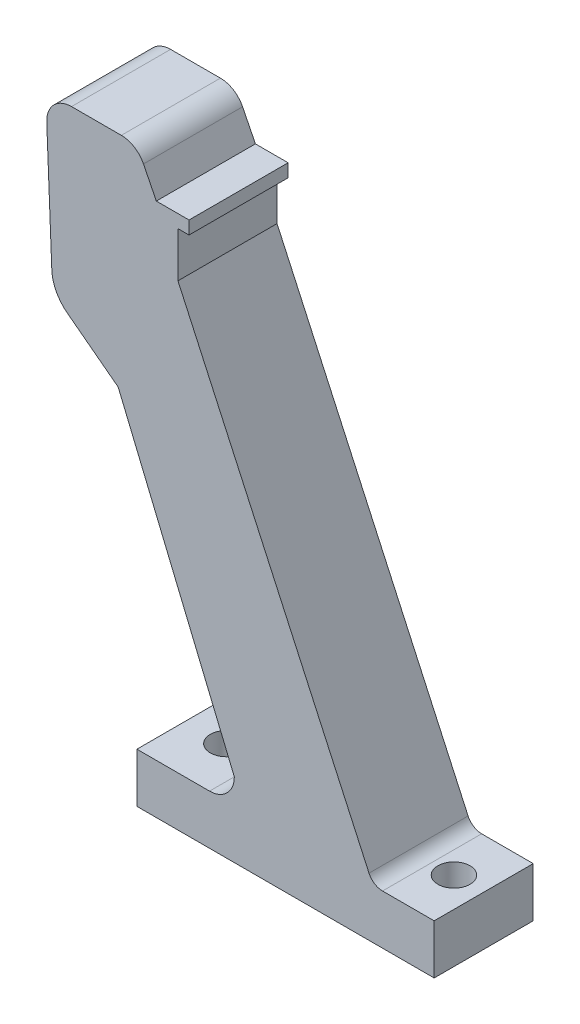
from build123d import *

# Parameters (mm, degrees)
BOSS_EXTRUDE1_DEPTH     = 20
SKETCH3_R               = 3.25
CUT_EXTRUDE1_DEPTH      = 20
CUT_EXTRUDE1_DEPTH_BACK = 20


with BuildPart() as part:
    # Sketch1 → Boss-Extrude1 (new body)
    with BuildSketch(Plane.XY):
        with BuildLine():
            Line((-44.097792079, -34.850100287), (-44.097792079, -44.850100287))
            Line((-44.097792079, -44.850100287), (15.902191644, -44.850100287))
            Line((15.902191644, -44.850100287), (15.902191644, -34.850100287))
            Line((15.902191644, -34.850100287), (5.481837679, -34.850100287))
            ThreePointArc((5.481837679, -34.850100287), (3.860980617, -34.374545252), (2.753994712, -33.098648543))
            Line((2.753994712, -33.098648543), (-35.815277858, 51.167953451))
            Line((-35.815277858, 51.167953451), (-35.815277858, 60.291959238))
            Line((-35.815277858, 60.291959238), (-33.576612404, 60.291959238))
            Line((-33.576612404, 60.291959238), (-33.576612404, 62.924734339))
            Line((-33.576612404, 62.924734339), (-40.180850679, 62.924734339))
            Line((-40.180850679, 62.924734339), (-42.770369484, 68.117950349))
            ThreePointArc((-42.770369484, 68.117950349), (-44.613967183, 70.138587546), (-47.244946047, 70.886770262))
            Line((-47.244946047, 70.886770262), (-57.300660313, 70.886770262))
            ThreePointArc((-57.300660313, 70.886770262), (-60.906449606, 69.350624123), (-62.296631179, 65.686083691))
            Line((-62.296631179, 65.686083691), (-61.293211228, 40.706550479))
            ThreePointArc((-61.293211228, 40.706550479), (-60.463803823, 37.168602153), (-58.148414135, 34.367894102))
            Line((-58.148414135, 34.367894102), (-47.87808719, 26.565161379))
            Line((-47.87808719, 26.565161379), (-24.43830161, -29.850100287))
            ThreePointArc((-24.43830161, -29.850100287), (-25.902767704, -33.385634193), (-29.43830161, -34.850100287))
            Line((-29.43830161, -34.850100287), (-35.915534593, -34.850100287))
            Line((-35.915534593, -34.850100287), (-44.097792079, -34.850100287))
        make_face()
    extrude(amount=BOSS_EXTRUDE1_DEPTH)

    # Sketch3 → Cut-Extrude1 (cut, two sides)
    with BuildSketch(Plane(origin=(0, -34.850100287, 0), x_dir=(1, 0, 0), z_dir=(0, 1, 0))) as cut_extrude1_sk:
        with Locations((9.902191644, -10)):
            Circle(SKETCH3_R)
        with Locations((-36.038433316, -10)):
            Circle(SKETCH3_R)
    extrude(amount=CUT_EXTRUDE1_DEPTH, mode=Mode.SUBTRACT)
    extrude(cut_extrude1_sk.sketch, amount=-CUT_EXTRUDE1_DEPTH_BACK, mode=Mode.SUBTRACT)


solid = part.part
